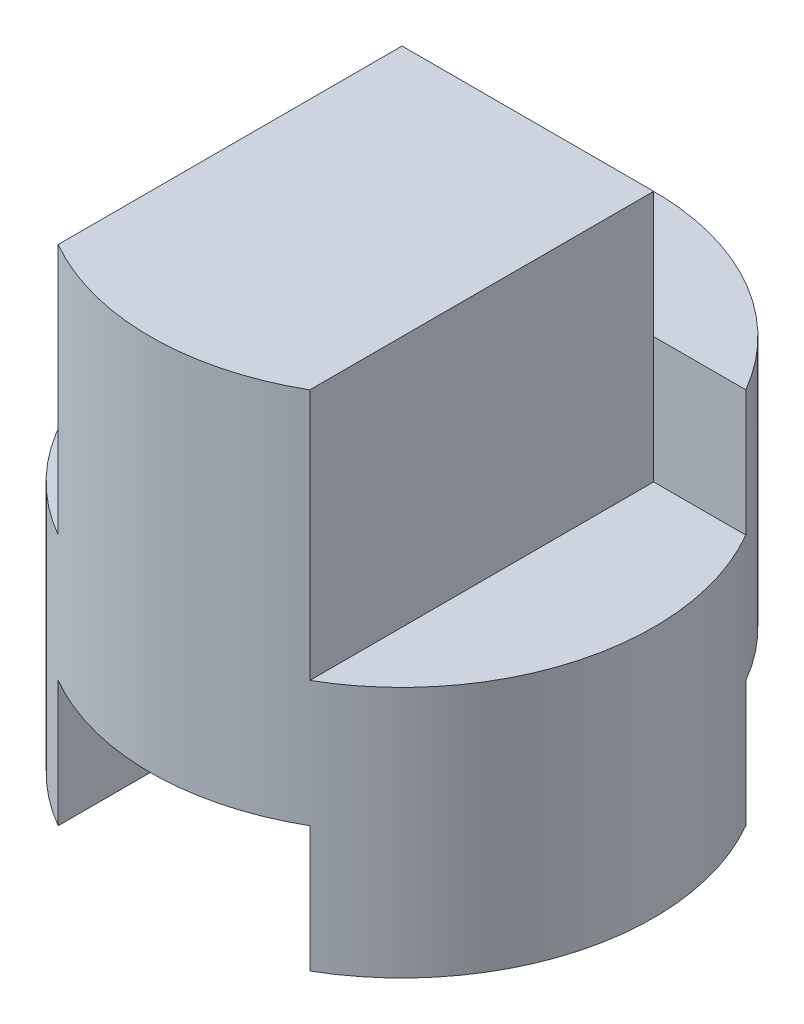
from build123d import *

# Parameters (mm, degrees)
SKETCH1_R               = 2
BOSS_EXTRUDE1_DEPTH     = 4
SKETCH2_W               = 2
SKETCH2_H               = 1
CUT_EXTRUDE1_DEPTH      = 2
CUT_EXTRUDE2_DEPTH      = 4
CUT_EXTRUDE2_DEPTH_BACK = 1
CUT_EXTRUDE3_DEPTH      = 1
CUT_EXTRUDE4_DEPTH      = 1


with BuildPart() as part:
    # Sketch1 → Boss-Extrude1 (new body)
    with BuildSketch(Plane(origin=(0, 0, 0), x_dir=(1, 0, 0), z_dir=(0, 1, 0))):
        Circle(SKETCH1_R)
    extrude(amount=BOSS_EXTRUDE1_DEPTH)

    # Sketch2 → Cut-Extrude1 (cut, symmetric)
    with BuildSketch(Plane.XY):
        with Locations((0, 0.5)):
            Rectangle(SKETCH2_W, SKETCH2_H)
    extrude(amount=CUT_EXTRUDE1_DEPTH, both=True, mode=Mode.SUBTRACT)

    # Sketch3 → Cut-Extrude2 (cut, two sides)
    with BuildSketch(Plane.XY) as cut_extrude2_sk:
        Polygon((2, 4), (2, 3), (2, 2), (0.999776138, 2), (0.999776138, 3), (0.999776138, 4), align=None)
        Polygon((-1, 2), (-2, 2), (-2, 4), (-1, 4), (-1, 3), align=None)
    extrude(amount=CUT_EXTRUDE2_DEPTH, mode=Mode.SUBTRACT)
    extrude(cut_extrude2_sk.sketch, amount=-CUT_EXTRUDE2_DEPTH_BACK, mode=Mode.SUBTRACT)

    # Sketch4 → Cut-Extrude3 (cut)
    with BuildSketch(Plane(origin=(0, 4, 0), x_dir=(1, 0, 0), z_dir=(0, 1, 0))):
        with BuildLine():
            Line((-1.732050808, 1), (1.732050808, 1))
            ThreePointArc((1.732050808, 1), (0, 2), (-1.732050808, 1))
        make_face()
    extrude(amount=-CUT_EXTRUDE3_DEPTH, mode=Mode.SUBTRACT)

    # Sketch5 → Cut-Extrude4 (cut)
    with BuildSketch(Plane.XZ):
        with BuildLine():
            Line((-1.732050808, -1), (1.732050808, -1))
            ThreePointArc((1.732050808, -1), (0, -2), (-1.732050808, -1))
        make_face()
    extrude(amount=-CUT_EXTRUDE4_DEPTH, mode=Mode.SUBTRACT)


solid = part.part
